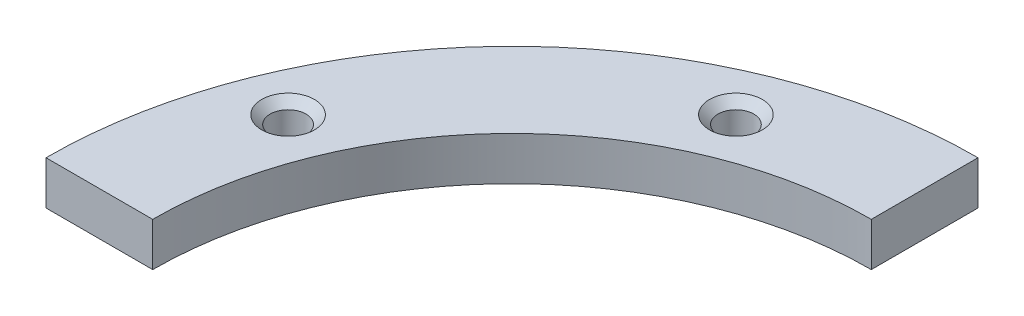
from build123d import *

# Parameters (mm, degrees)
BOSS_EXTRUDE1_DEPTH         = 4
M4_TAPPED_HOLE1_D           = 3.3
M4_TAPPED_HOLE1_CSINK_D     = 4.85
M4_TAPPED_HOLE1_CSINK_ANGLE = 90
CIRPATTERN1_COUNT           = 8


with BuildPart() as part:
    # Sketch1 → Boss-Extrude1 (new body)
    with BuildSketch(Plane(origin=(0, 0, 0), x_dir=(1, 0, 0), z_dir=(0, 1, 0))):
        with BuildLine():
            Line((0, 33), (0, 42.8))
            ThreePointArc((0, 42.8), (-30.264170235, 30.264170235), (-42.8, 0))
            Line((-42.8, 0), (-33, 0))
            ThreePointArc((-33, 0), (-23.334523779, 23.334523779), (0, 33))
        make_face()
    extrude(amount=BOSS_EXTRUDE1_DEPTH)

    # M4 Tapped Hole1 (through all)
    with Locations(Plane(origin=(0, 4, 0), x_dir=(1, 0, 0), z_dir=(0, 1, 0))):
        with Locations((-35.107422235, 14.54197043)):
            m4_tapped_hole1 = CounterSinkHole(M4_TAPPED_HOLE1_D / 2, M4_TAPPED_HOLE1_CSINK_D / 2, counter_sink_angle=M4_TAPPED_HOLE1_CSINK_ANGLE)

    # CirPattern1: M4 Tapped Hole1 ×8 about axis, 6 skipped
    cirpattern1_axis = Axis((0, 4, 0), (0, 1, 0))
    add([m4_tapped_hole1.rotate(cirpattern1_axis, i * 360 / CIRPATTERN1_COUNT) for i in range(1, CIRPATTERN1_COUNT) if i not in (1, 2, 3, 4, 5, 6)], mode=Mode.SUBTRACT)


solid = part.part
